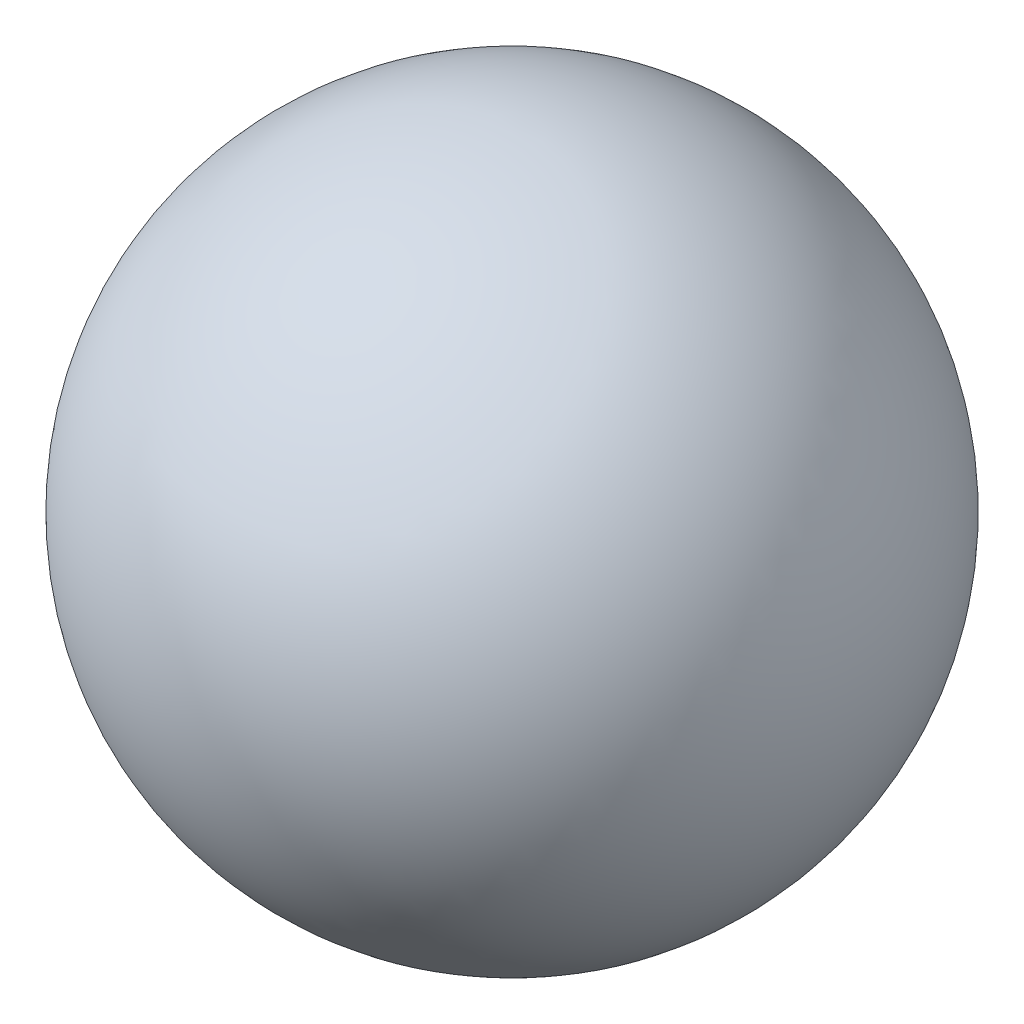
from build123d import *


with BuildPart() as part:
    # Sketch1 → Revolve1 (revolve)
    with BuildSketch(Plane.XY):
        with BuildLine():
            Line((0, 119.85625), (0, -119.85625))
            ThreePointArc((0, -119.85625), (119.85625, 0), (0, 119.85625))
        make_face()
    revolve(axis=Axis((0, 119.85625, 0), (0, -1, 0)))


solid = part.part
